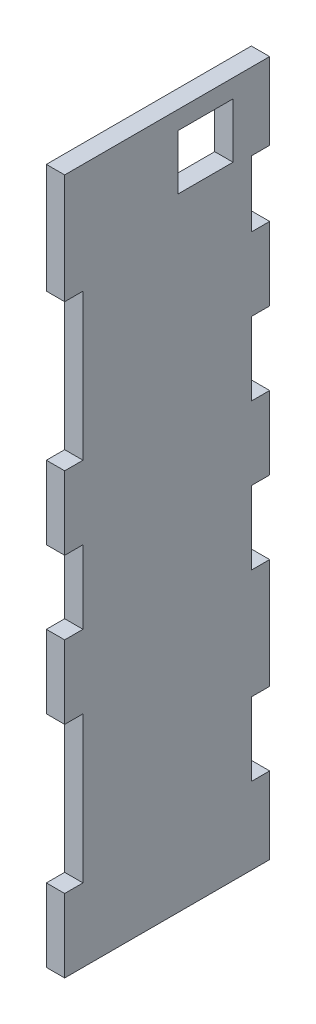
from build123d import *

# Parameters (mm, degrees)
SKETCH1_W           = 6.35
SKETCH1_H           = 241.3
BOSS_EXTRUDE1_DEPTH = 71.12
SKETCH2_W           = 6.35
SKETCH2_H           = 22.86
SKETCH2_H_2         = 25.4
CUT_EXTRUDE1_DEPTH  = 6.35
SKETCH3_W           = 6.35
SKETCH3_H           = 50.8
SKETCH3_H_2         = 25.4
CUT_EXTRUDE2_DEPTH  = 6.35
SKETCH4_W           = 19.05
SKETCH4_H           = 19.05
CUT_EXTRUDE3_DEPTH  = 7.35


with BuildPart() as part:
    # Sketch1 → Boss-Extrude1 (new body)
    with BuildSketch(Plane.XY):
        with Locations((-136.525, -120.65)):
            Rectangle(SKETCH1_W, SKETCH1_H)
    extrude(amount=-BOSS_EXTRUDE1_DEPTH)

    # Sketch2 → Cut-Extrude1 (cut)
    with BuildSketch(Plane(origin=(-133.35, 0, 0), x_dir=(0, 0, -1), z_dir=(1, 0, 0))):
        with Locations((67.945, -38.1)):
            Rectangle(SKETCH2_W, SKETCH2_H)
        with Locations((67.945, -87.63)):
            Rectangle(SKETCH2_W, SKETCH2_H_2)
        with Locations((67.945, -138.43)):
            Rectangle(SKETCH2_W, SKETCH2_H_2)
        with Locations((67.945, -201.93)):
            Rectangle(SKETCH2_W, SKETCH2_H_2)
    extrude(amount=-CUT_EXTRUDE1_DEPTH, mode=Mode.SUBTRACT)

    # Sketch3 → Cut-Extrude2 (cut)
    with BuildSketch(Plane(origin=(-133.35, 0, 0), x_dir=(0, 0, -1), z_dir=(1, 0, 0))):
        with Locations((3.175, -190.5)):
            Rectangle(SKETCH3_W, SKETCH3_H)
        with Locations((3.175, -127)):
            Rectangle(SKETCH3_W, SKETCH3_H_2)
        with Locations((3.175, -63.5)):
            Rectangle(SKETCH3_W, SKETCH3_H)
    extrude(amount=-CUT_EXTRUDE2_DEPTH, mode=Mode.SUBTRACT)

    # Sketch4 → Cut-Extrude3 (cut, through all)
    with BuildSketch(Plane.ZY.offset(139.7)):
        with Locations((-48.895, -15.875)):
            Rectangle(SKETCH4_W, SKETCH4_H)
    extrude(amount=-CUT_EXTRUDE3_DEPTH, mode=Mode.SUBTRACT)


solid = part.part
